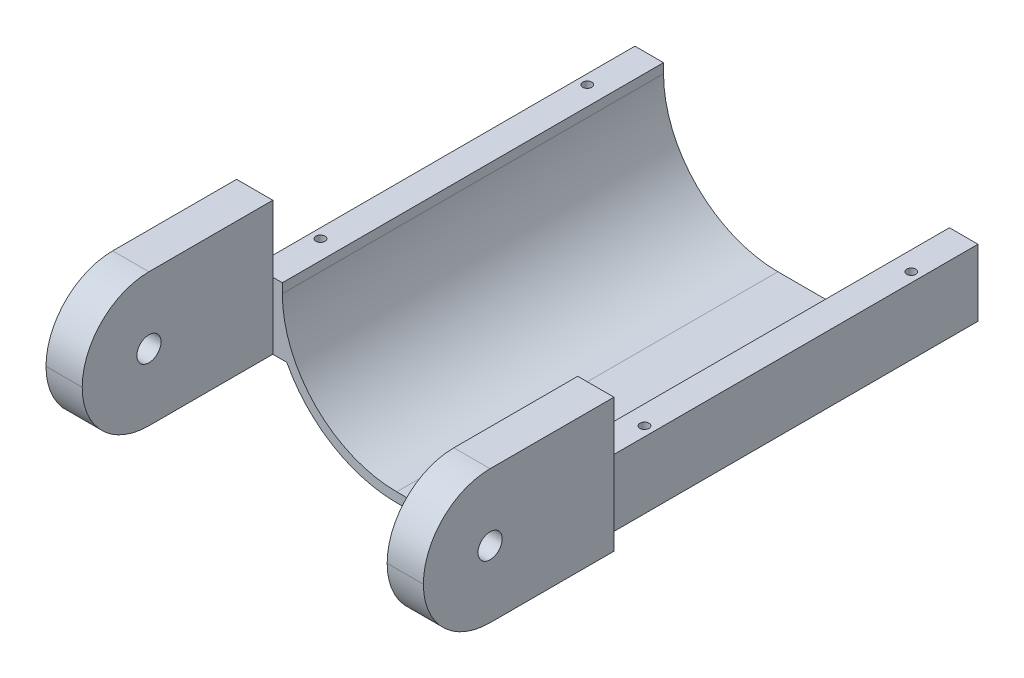
from build123d import *

# Parameters (mm, degrees)
SKETCH1_W           = 10
SKETCH1_H           = 5
BOSS_EXTRUDE1_DEPTH = 200
SKETCH2_R           = 2.38125
CUT_EXTRUDE1_DEPTH  = 200
SKETCH3_W           = 10
SKETCH3_H           = 30
SKETCH3_H_2         = 5
BOSS_EXTRUDE2_DEPTH = 100
CUT_EXTRUDE2_DEPTH  = 100
BOSS_EXTRUDE5_START = -15
SKETCH5_R           = 6.35
BOSS_EXTRUDE5_DEPTH = 15
SKETCH6_R           = 6.35
BOSS_EXTRUDE6_DEPTH = 5
BOSS_EXTRUDE7_START = -200
BOSS_EXTRUDE7_DEPTH = 200
SKETCH8_R           = 6.35
BOSS_EXTRUDE8_DEPTH = 9
SKETCH9_R           = 6.35
BOSS_EXTRUDE9_DEPTH = 9
SKETCH10_R          = 6.35
CUT_EXTRUDE3_DEPTH  = 5
SKETCH11_R          = 6.35
CUT_EXTRUDE4_DEPTH  = 5
SKETCH12_R          = 2.38125
CUT_EXTRUDE5_DEPTH  = 66


with BuildPart() as part:
    # Sketch1 → Boss-Extrude1 (new body)
    with BuildSketch(Plane.XY):
        with Locations((-10, 62.5)):
            Rectangle(SKETCH1_W, SKETCH1_H)
        with BuildLine():
            Line((90, 0), (60, 0))
            ThreePointArc((60, 0), (17.573593, 17.573593), (0, 60))
            Line((0, 60), (0, 65))
            Line((0, 65), (-5, 65))
            Line((-5, 65), (-5, 60))
            ThreePointArc((-5, 60), (14.038059, 14.038059), (60, -5))
            Line((60, -5), (90, -5))
            ThreePointArc((90, -5), (135.961941, 14.038059), (155, 60))
            Line((155, 60), (155, 65))
            Line((155, 65), (150, 65))
            Line((150, 65), (150, 60))
            ThreePointArc((150, 60), (132.426407, 17.573593), (90, 0))
        make_face()
        with Locations((160, 62.5)):
            Rectangle(SKETCH1_W, SKETCH1_H)
    extrude(amount=BOSS_EXTRUDE1_DEPTH)

    # Sketch2 → Cut-Extrude1 (cut)
    with BuildSketch(Plane(origin=(0, 65, 0), x_dir=(1, 0, 0), z_dir=(0, 1, 0))):
        with Locations((-10, -170)):
            Circle(SKETCH2_R)
        with Locations((-10, -30)):
            Circle(SKETCH2_R)
        with Locations((160, -30)):
            Circle(SKETCH2_R)
        with Locations((160, -170)):
            Circle(SKETCH2_R)
    extrude(amount=-CUT_EXTRUDE1_DEPTH, mode=Mode.SUBTRACT)

    # Sketch3 → Boss-Extrude2 (add)
    with BuildSketch(Plane.XY.offset(200)):
        with Locations((-10, 45)):
            Rectangle(SKETCH3_W, SKETCH3_H)
        with Locations((-10, 62.5)):
            Rectangle(SKETCH3_W, SKETCH3_H_2)
        with Locations((-10, 67.5)):
            Rectangle(SKETCH3_W, SKETCH3_H_2)
        with Locations((-10, 85)):
            Rectangle(SKETCH3_W, SKETCH3_H)
    extrude(amount=BOSS_EXTRUDE2_DEPTH)

    # Sketch4 → Cut-Extrude2 (cut)
    with BuildSketch(Plane(origin=(-5, 0, 0), x_dir=(0, 0, -1), z_dir=(1, 0, 0))):
        with BuildLine():
            ThreePointArc((-260.509872, 69.490128), (-269.490128, 69.490128), (-269.490128, 60.509872))
            Line((-269.490128, 60.509872), (-260.509872, 69.490128))
        make_face()
        with BuildLine():
            Line((-260.509872, 69.490128), (-269.490128, 60.509872))
            ThreePointArc((-269.490128, 60.509872), (-262.56996, 59.133365), (-258.65, 65))
            ThreePointArc((-258.65, 65), (-259.133365, 67.43004), (-260.509872, 69.490128))
        make_face()
        with BuildLine():
            Line((-300, 30), (-265.01, 30))
            ThreePointArc((-265.01, 30), (-278.400093, 32.663455), (-289.751666, 40.248334))
            Line((-289.751666, 40.248334), (-300, 30))
        make_face()
        with BuildLine():
            Line((-300, 30), (-289.751666, 40.248334))
            ThreePointArc((-289.751666, 40.248334), (-297.336545, 51.599907), (-300, 64.99))
            Line((-300, 64.99), (-300, 30))
        make_face()
        with BuildLine():
            ThreePointArc((-300, 65.01), (-289.751666, 89.751666), (-265.01, 100))
            Line((-265.01, 100), (-300, 100))
            Line((-300, 100), (-300, 65.01))
        make_face()
    extrude(amount=-CUT_EXTRUDE2_DEPTH, mode=Mode.SUBTRACT)

    # Sketch5 → Boss-Extrude5 (add)
    with BuildSketch(Plane(origin=(165, 0, 0), x_dir=(0, 0, -1), z_dir=(1, 0, 0)).offset(BOSS_EXTRUDE5_START)):
        with BuildLine():
            Line((-300, 65.01), (-300, 64.99))
            ThreePointArc((-300, 64.99), (-289.751666, 40.248334), (-265.01, 30))
            Line((-265.01, 30), (-200, 30))
            Line((-200, 30), (-200, 60))
            Line((-200, 60), (-200, 65))
            Line((-200, 65), (-200, 100))
            Line((-200, 100), (-265.01, 100))
            ThreePointArc((-265.01, 100), (-289.751666, 89.751666), (-300, 65.01))
        make_face()
        with Locations((-265, 65)):
            Circle(SKETCH5_R, mode=Mode.SUBTRACT)
    extrude(amount=BOSS_EXTRUDE5_DEPTH)

    # Sketch6 → Boss-Extrude6 (add)
    with BuildSketch(Plane(origin=(-5, 0, 0), x_dir=(0, 0, -1), z_dir=(1, 0, 0))):
        with BuildLine():
            Line((-300, 65.01), (-300, 64.99))
            ThreePointArc((-300, 64.99), (-289.751666, 40.248334), (-265.01, 30))
            Line((-265.01, 30), (-200, 30))
            Line((-200, 30), (-200, 60))
            Line((-200, 60), (-200, 65))
            Line((-200, 65), (-200, 100))
            Line((-200, 100), (-265.01, 100))
            ThreePointArc((-265.01, 100), (-289.751666, 89.751666), (-300, 65.01))
        make_face()
        with Locations((-265, 65)):
            Circle(SKETCH6_R, mode=Mode.SUBTRACT)
    extrude(amount=BOSS_EXTRUDE6_DEPTH)

    # Sketch7 → Boss-Extrude7 (add)
    with BuildSketch(Plane(origin=(0, 0, 0), x_dir=(-1, 0, 0), z_dir=(0, 0, -1)).offset(BOSS_EXTRUDE7_START)):
        with BuildLine():
            Line((-150, 35), (-150, 30))
            Line((-150, 30), (-147.662813, 30))
            ThreePointArc((-147.662813, 30), (-148.8845, 32.475182), (-150, 35))
        make_face()
        with BuildLine():
            Line((-165, 60), (-165, 30))
            Line((-165, 30), (-150, 30))
            Line((-150, 30), (-150, 35))
            ThreePointArc((-150, 35), (-153.737744, 47.252451), (-155, 60))
            Line((-155, 60), (-165, 60))
        make_face()
        with BuildLine():
            ThreePointArc((0, 35), (-1.1155, 32.475182), (-2.337187, 30))
            Line((-2.337187, 30), (0, 30))
            Line((0, 30), (0, 35))
        make_face()
        with BuildLine():
            Line((0, 35), (0, 30))
            Line((0, 30), (5, 30))
            Line((5, 30), (15, 30))
            Line((15, 30), (15, 60))
            Line((15, 60), (5, 60))
            ThreePointArc((5, 60), (3.737744, 47.252451), (0, 35))
        make_face()
    extrude(amount=BOSS_EXTRUDE7_DEPTH)

    # Sketch8 → Boss-Extrude8 (add)
    with BuildSketch(Plane(origin=(165, 0, 0), x_dir=(0, 0, -1), z_dir=(1, 0, 0))):
        with BuildLine():
            Line((-200, 65), (-200, 100))
            Line((-200, 100), (-265.01, 100))
            ThreePointArc((-265.01, 100), (-289.751666, 89.751666), (-300, 65.01))
            Line((-300, 65.01), (-300, 64.99))
            ThreePointArc((-300, 64.99), (-289.751666, 40.248334), (-265.01, 30))
            Line((-265.01, 30), (-200, 30))
            Line((-200, 30), (-200, 65))
        make_face()
        with Locations((-265, 65)):
            Circle(SKETCH8_R, mode=Mode.SUBTRACT)
    extrude(amount=BOSS_EXTRUDE8_DEPTH)

    # Sketch9 → Boss-Extrude9 (add)
    with BuildSketch(Plane.ZY.offset(15)):
        with BuildLine():
            Line((265.01, 100), (200, 100))
            Line((200, 100), (200, 65))
            Line((200, 65), (200, 30))
            Line((200, 30), (265.01, 30))
            ThreePointArc((265.01, 30), (289.751666, 40.248334), (300, 64.99))
            Line((300, 64.99), (300, 65.01))
            ThreePointArc((300, 65.01), (289.751666, 89.751666), (265.01, 100))
        make_face()
        with Locations((265, 65)):
            Circle(SKETCH9_R, mode=Mode.SUBTRACT)
    extrude(amount=BOSS_EXTRUDE9_DEPTH)

    # Sketch10 → Cut-Extrude3 (cut)
    with BuildSketch(Plane.ZY.offset(-150)):
        with BuildLine():
            Line((200, 60), (200, 65))
            Line((200, 65), (200, 100))
            Line((200, 100), (265.01, 100))
            ThreePointArc((265.01, 100), (289.751666, 89.751666), (300, 65.01))
            Line((300, 65.01), (300, 64.99))
            ThreePointArc((300, 64.99), (289.751666, 40.248334), (265.01, 30))
            Line((265.01, 30), (200, 30))
            Line((200, 30), (200, 60))
        make_face()
        with Locations((265, 65)):
            Circle(SKETCH10_R, mode=Mode.SUBTRACT)
    extrude(amount=-CUT_EXTRUDE3_DEPTH, mode=Mode.SUBTRACT)

    # Sketch11 → Cut-Extrude4 (cut)
    with BuildSketch(Plane(origin=(0, 0, 0), x_dir=(0, 0, -1), z_dir=(1, 0, 0))):
        with BuildLine():
            Line((-200, 60), (-200, 65))
            Line((-200, 65), (-200, 100))
            Line((-200, 100), (-265.01, 100))
            ThreePointArc((-265.01, 100), (-289.751666, 89.751666), (-300, 65.01))
            Line((-300, 65.01), (-300, 64.99))
            ThreePointArc((-300, 64.99), (-289.751666, 40.248334), (-265.01, 30))
            Line((-265.01, 30), (-200, 30))
            Line((-200, 30), (-200, 60))
        make_face()
        with Locations((-265, 65)):
            Circle(SKETCH11_R, mode=Mode.SUBTRACT)
    extrude(amount=-CUT_EXTRUDE4_DEPTH, mode=Mode.SUBTRACT)

    # Sketch12 → Cut-Extrude5 (cut, through all)
    with BuildSketch(Plane(origin=(0, 60, 0), x_dir=(1, 0, 0), z_dir=(0, 1, 0))):
        with Locations((160, -30)):
            Circle(SKETCH12_R)
        with Locations((-10, -170)):
            Circle(SKETCH12_R)
        with Locations((-10, -30)):
            Circle(SKETCH12_R)
        with Locations((160, -170)):
            Circle(SKETCH12_R)
    extrude(amount=-CUT_EXTRUDE5_DEPTH, mode=Mode.SUBTRACT)


solid = part.part
